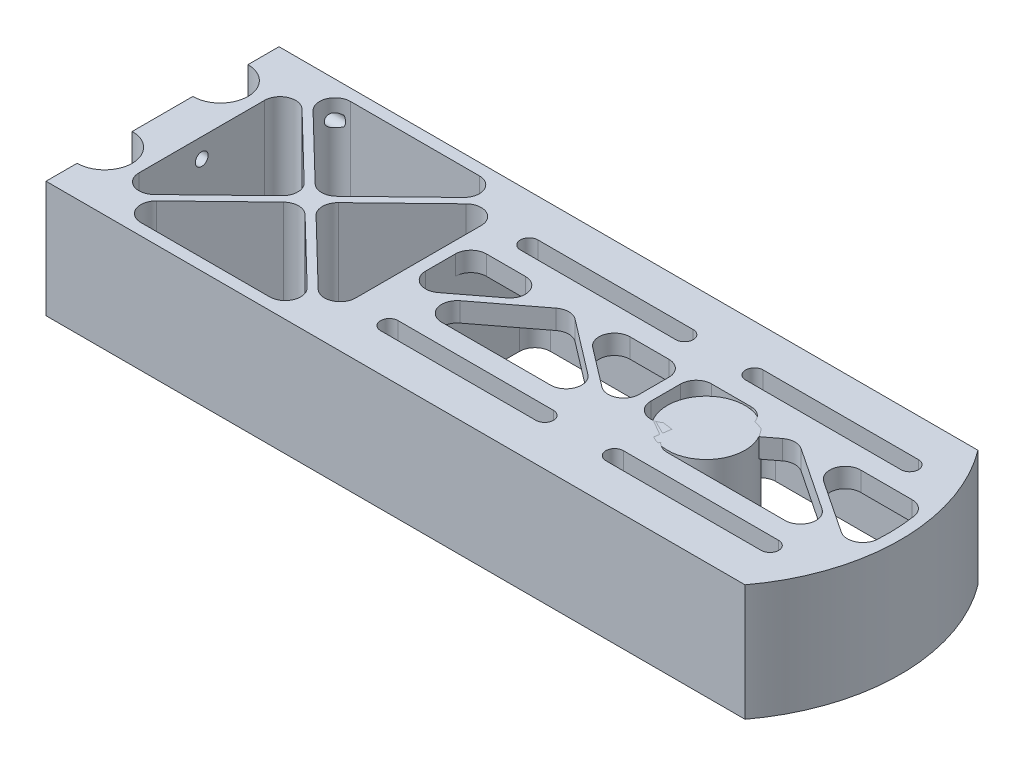
from build123d import *

# Parameters (mm, degrees)
EXTRUDE_1_DEPTH      = 30
CUT_EXTRUDE_1_DEPTH  = 31
TEMP_R               = 10
EXTRUDE_2_DEPTH      = 30
EXTRUDE_3_DEPTH      = 5
EXTRUDE_4_DEPTH      = 30
SKETCH_6_W           = 3
SKETCH_6_H           = 54
EXTRUDE_5_DEPTH      = 30
EXTRUDE_6_DEPTH      = 30
SKETCH_9_W           = 3
SKETCH_9_H           = 54
EXTRUDE_8_DEPTH      = 25
EXTRUDE_8_DEPTH_BACK = 5
EXTRUDE_7_DEPTH      = 5
FILLET_1_R           = 4
FILLET_2_R           = 4
FILLET_3_R           = 4
EXTRUDE_9_DEPTH      = 5
M4X0_71_AT_2_COUNT   = 2
M4X0_71_AT_2_PITCH   = 25.75
M4X0_71_AT_3_COUNT   = 2
M4X0_71_AT_3_PITCH   = 51.5
M4X0_71_AT_4_COUNT   = 2
M4X0_71_AT_4_PITCH   = 55.247171873
M4X0_71_AT_5_COUNT   = 2
M4X0_71_AT_5_PITCH   = 32.60463924
M4X0_71_AT_6_COUNT   = 2
M4X0_71_AT_6_PITCH   = 20


with BuildPart() as part:
    # Эскиз1 → Бобышка-Вытянуть1 (new body)
    with BuildSketch(Plane(origin=(0, 0, 0), x_dir=(1, 0, 0), z_dir=(0, 1, 0))):
        with BuildLine():
            Line((0, 60), (180, 60))
            ThreePointArc((180, 60), (190, 30), (180, 0))
            Line((180, 0), (0, 0))
            Line((0, 0), (0, 8))
            ThreePointArc((0, 8), (7.1, 15.1), (0, 22.2))
            Line((0, 22.2), (0, 37.8))
            ThreePointArc((0, 37.8), (7.1, 44.9), (0, 52))
            Line((0, 52), (0, 60))
        make_face()
    extrude(amount=EXTRUDE_1_DEPTH)

    # Эскиз2 → Вырез-Вытянуть1 (cut, through all)
    with BuildSketch(Plane(origin=(0, 30, 0), x_dir=(1, 0, 0), z_dir=(0, 1, 0))):
        with BuildLine():
            Line((3, 3), (178.470768123, 3))
            ThreePointArc((178.470768123, 3), (187, 30), (178.470768123, 57))
            Line((178.470768123, 57), (3, 57))
            Line((3, 57), (3, 54.544169223))
            ThreePointArc((3, 54.544169223), (10.1, 44.9), (3, 35.255830777))
            Line((3, 35.255830777), (3, 24.744169223))
            ThreePointArc((3, 24.744169223), (10.1, 15.1), (3, 5.455830777))
            Line((3, 5.455830777), (3, 3))
        make_face()
    extrude(amount=-CUT_EXTRUDE_1_DEPTH, mode=Mode.SUBTRACT)

    # Эскиз3 → Бобышка-Вытянуть3 (add)
    with BuildSketch(Plane(origin=(0, 30, 0), x_dir=(1, 0, 0), z_dir=(0, 1, 0))):
        with BuildLine():
            Line((178.470768123, 57), (68.916586692, 57))
            Line((68.916586692, 57), (68.916586692, 40.5))
            Line((68.916586692, 40.5), (185.812116301, 40.5))
            ThreePointArc((185.812116301, 40.5), (182.941397878, 49.105924428), (178.470768123, 57))
        make_face()
        with BuildLine():
            Line((116.416586692, 43.5), (76.416586692, 43.5))
            ThreePointArc((76.416586692, 43.5), (71.916586692, 48), (76.416586692, 52.5))
            Line((76.416586692, 52.5), (116.416586692, 52.5))
            ThreePointArc((116.416586692, 52.5), (120.916586692, 48), (116.416586692, 43.5))
        make_face(mode=Mode.SUBTRACT)
        with BuildLine():
            ThreePointArc((174.416586692, 52.5), (178.916586692, 48), (174.416586692, 43.5))
            Line((174.416586692, 43.5), (134.416586692, 43.5))
            ThreePointArc((134.416586692, 43.5), (129.916586692, 48), (134.416586692, 52.5))
            Line((134.416586692, 52.5), (174.416586692, 52.5))
        make_face(mode=Mode.SUBTRACT)
        with BuildLine():
            ThreePointArc((178.470768123, 3), (182.941397878, 10.894075572), (185.812116301, 19.5))
            Line((185.812116301, 19.5), (68.916586692, 19.5))
            Line((68.916586692, 19.5), (68.916586692, 3))
            Line((68.916586692, 3), (178.470768123, 3))
        make_face()
        with BuildLine():
            ThreePointArc((76.416586692, 7.5), (71.916586692, 12), (76.416586692, 16.5))
            Line((76.416586692, 16.5), (116.416586692, 16.5))
            ThreePointArc((116.416586692, 16.5), (120.916586692, 12), (116.416586692, 7.5))
            Line((116.416586692, 7.5), (76.416586692, 7.5))
        make_face(mode=Mode.SUBTRACT)
        with BuildLine():
            Line((134.416586692, 16.5), (174.416586692, 16.5))
            ThreePointArc((174.416586692, 16.5), (178.916586692, 12), (174.416586692, 7.5))
            Line((174.416586692, 7.5), (134.416586692, 7.5))
            ThreePointArc((134.416586692, 7.5), (129.916586692, 12), (134.416586692, 16.5))
        make_face(mode=Mode.SUBTRACT)
    extrude(amount=-EXTRUDE_3_DEPTH)

    # Эскиз4 → Бобышка-Вытянуть4 (add, through all)
    with BuildSketch(Plane(origin=(0, 30, 0), x_dir=(1, 0, 0), z_dir=(0, 1, 0))):
        with BuildLine():
            Line((10.1, 57), (3, 57))
            Line((3, 57), (3, 54.544169223))
            ThreePointArc((3, 54.544169223), (8.133572401, 50.887904475), (10.1, 44.9))
            Line((10.1, 44.9), (10.1, 57))
        make_face()
        with BuildLine():
            Line((10.1, 15.099999916), (10.1, 44.9))
            ThreePointArc((10.1, 44.9), (8.133572401, 38.912095525), (3, 35.255830777))
            Line((3, 35.255830777), (3, 24.744169223))
            ThreePointArc((3, 24.744169223), (8.133572426, 21.087904441), (10.1, 15.099999916))
        make_face()
        with BuildLine():
            Line((10.1, 3), (10.1, 15.099999916))
            ThreePointArc((10.1, 15.099999916), (8.133572376, 9.112095491), (3, 5.455830777))
            Line((3, 5.455830777), (3, 3))
            Line((3, 3), (10.1, 3))
        make_face()
    extrude(amount=-EXTRUDE_4_DEPTH)

    # Эскиз6 → Бобышка-Вытянуть5 (add, through all)
    with BuildSketch(Plane(origin=(0, 30, 0), x_dir=(1, 0, 0), z_dir=(0, 1, 0))):
        with Locations((67.416586692, 30)):
            Rectangle(SKETCH_6_W, SKETCH_6_H)
    extrude(amount=-EXTRUDE_5_DEPTH)

    # Эскиз7 → Бобышка-Вытянуть6 (add, through all)
    with BuildSketch(Plane(origin=(0, 30, 0), x_dir=(1, 0, 0), z_dir=(0, 1, 0))):
        Polygon((10.1, 55.608609353), (36.57009563, 30), (10.1, 4.391390647), (10.1, 3), (11.538197716, 3), (38.008293346, 28.608609353), (64.478388976, 3), (65.916586692, 3), (65.916586692, 4.391390647), (39.446491062, 30), (65.916586692, 55.608609353), (65.916586692, 57), (64.478388976, 57), (38.008293346, 31.391390647), (11.538197716, 57), (10.1, 57), align=None)
    extrude(amount=-EXTRUDE_6_DEPTH)

    # Эскиз9 → Бобышка-Вытянуть8 (add, two sides)
    with BuildSketch(Plane.XZ.offset(-25)) as extrude_8_sk:
        with Locations((125.416586692, -30)):
            Rectangle(SKETCH_9_W, SKETCH_9_H)
    extrude(amount=EXTRUDE_8_DEPTH)
    extrude(extrude_8_sk.sketch, amount=-EXTRUDE_8_DEPTH_BACK)

    # Эскиз8 → Бобышка-Вытянуть7 (add)
    with BuildSketch(Plane(origin=(0, 30, 0), x_dir=(1, 0, 0), z_dir=(0, 1, 0))):
        Polygon((70.564267671, 19.5), (96.416586692, 39.241770889), (122.268905713, 19.5), (123.916586692, 19.5), (123.916586692, 20.758229111), (98.064267671, 40.5), (94.768905713, 40.5), (68.916586692, 20.758229111), (68.916586692, 19.5), align=None)
        with BuildLine():
            Line((128.569887735, 19.5), (154.477979009, 39.178204914))
            Line((154.477979009, 39.178204914), (184.008770478, 19.5))
            Line((184.008770478, 19.5), (185.812116301, 19.5))
            ThreePointArc((185.812116301, 19.5), (185.929117822, 20.024222532), (186.040120933, 20.549747915))
            Line((186.040120933, 20.549747915), (156.101072293, 40.5))
            Line((156.101072293, 40.5), (152.911636662, 40.5))
            Line((152.911636662, 40.5), (126.916586692, 20.755746568))
            Line((126.916586692, 20.755746568), (126.916586692, 19.5))
            Line((126.916586692, 19.5), (128.569887735, 19.5))
        make_face()
    extrude(amount=-EXTRUDE_7_DEPTH)

    # Скругление1
    fillet_1_edges = [part.edges().sort_by_distance(p)[0] for p in [
        (10.1, 15, -4.391390647),
        (36.57009563, 15, -30),
        (10.1, 15, -55.608609353),
        (11.538197716, 15, -57),
        (38.008293346, 15, -31.391390647),
        (64.478388976, 15, -57),
        (65.916586692, 15, -55.608609353),
        (39.446491062, 15, -30),
        (65.916586692, 15, -4.391390647),
        (64.478388976, 15, -3),
        (38.008293346, 15, -28.608609353),
        (11.538197716, 15, -3),
    ]]
    fillet(fillet_1_edges, radius=FILLET_1_R)

    # Скругление2
    fillet_2_edges = [part.edges().sort_by_distance(p)[0] for p in [
        (68.916586692, 12.5, -57),
        (68.916586692, 12.5, -3),
        (123.916586692, 12.5, -57),
        (126.916586692, 12.5, -3),
        (123.916586692, 12.5, -3),
        (126.916586692, 12.5, -57),
        (178.470768123, 12.5, -57),
        (178.470768123, 12.5, -3),
    ]]
    fillet(fillet_2_edges, radius=FILLET_2_R)

    # Скругление3
    fillet_3_edges = [part.edges().sort_by_distance(p)[0] for p in [
        (123.916586692, 27.5, -40.5),
        (126.916586692, 27.5, -40.5),
        (70.564267671, 27.5, -19.5),
        (68.916586692, 27.5, -20.758229111),
        (94.768905713, 27.5, -40.5),
        (98.064267671, 27.5, -40.5),
        (123.916586692, 27.5, -20.758229111),
        (122.268905713, 27.5, -19.5),
        (96.416586692, 27.5, -39.241770889),
        (128.569887735, 27.5, -19.5),
        (126.916586692, 27.5, -20.755746568),
        (152.911636662, 27.5, -40.5),
        (156.101072293, 27.5, -40.5),
        (186.040120933, 27.5, -20.549747915),
        (184.008770478, 27.5, -19.5),
        (154.477979009, 27.5, -39.178204914),
        (68.916586692, 27.5, -40.5),
        (185.812116301, 27.5, -40.5),
    ]]
    fillet(fillet_3_edges, radius=FILLET_3_R)

    # Эскиз10 → Бобышка-Вытянуть9 (add)
    with BuildSketch(Plane(origin=(0, 30, 0), x_dir=(1, 0, 0), z_dir=(0, 1, 0))):
        with BuildLine():
            Line((76.416586692, 52.5), (116.416586692, 52.5))
            ThreePointArc((116.416586692, 52.5), (120.916586692, 48), (116.416586692, 43.5))
            Line((116.416586692, 43.5), (76.416586692, 43.5))
            ThreePointArc((76.416586692, 43.5), (71.916586692, 48), (76.416586692, 52.5))
        make_face()
        with BuildLine():
            Line((116.416586692, 50.25), (76.416586692, 50.25))
            ThreePointArc((76.416586692, 50.25), (74.166586692, 48), (76.416586692, 45.75))
            Line((76.416586692, 45.75), (116.416586692, 45.75))
            ThreePointArc((116.416586692, 45.75), (118.666586692, 48), (116.416586692, 50.25))
        make_face(mode=Mode.SUBTRACT)
        with BuildLine():
            Line((174.416586692, 52.5), (134.416586692, 52.5))
            ThreePointArc((134.416586692, 52.5), (129.916586692, 48), (134.416586692, 43.5))
            Line((134.416586692, 43.5), (174.416586692, 43.5))
            ThreePointArc((174.416586692, 43.5), (178.916586692, 48), (174.416586692, 52.5))
        make_face()
        with BuildLine():
            Line((174.416586692, 45.75), (134.416586692, 45.75))
            ThreePointArc((134.416586692, 45.75), (132.166586692, 48), (134.416586692, 50.25))
            Line((134.416586692, 50.25), (174.416586692, 50.25))
            ThreePointArc((174.416586692, 50.25), (176.666586692, 48), (174.416586692, 45.75))
        make_face(mode=Mode.SUBTRACT)
        with BuildLine():
            Line((76.416586692, 16.5), (116.416586692, 16.5))
            ThreePointArc((116.416586692, 16.5), (120.916586692, 12), (116.416586692, 7.5))
            Line((116.416586692, 7.5), (76.416586692, 7.5))
            ThreePointArc((76.416586692, 7.5), (71.916586692, 12), (76.416586692, 16.5))
        make_face()
        with BuildLine():
            Line((76.416586692, 9.75), (116.416586692, 9.75))
            ThreePointArc((116.416586692, 9.75), (118.666586692, 12), (116.416586692, 14.25))
            Line((116.416586692, 14.25), (76.416586692, 14.25))
            ThreePointArc((76.416586692, 14.25), (74.166586692, 12), (76.416586692, 9.75))
        make_face(mode=Mode.SUBTRACT)
        with BuildLine():
            Line((174.416586692, 16.5), (134.416586692, 16.5))
            ThreePointArc((134.416586692, 16.5), (129.916586692, 12), (134.416586692, 7.5))
            Line((134.416586692, 7.5), (174.416586692, 7.5))
            ThreePointArc((174.416586692, 7.5), (178.916586692, 12), (174.416586692, 16.5))
        make_face()
        with BuildLine():
            Line((174.416586692, 14.25), (134.416586692, 14.25))
            ThreePointArc((134.416586692, 14.25), (132.166586692, 12), (134.416586692, 9.75))
            Line((134.416586692, 9.75), (174.416586692, 9.75))
            ThreePointArc((174.416586692, 9.75), (176.666586692, 12), (174.416586692, 14.25))
        make_face(mode=Mode.SUBTRACT)
    extrude(amount=-EXTRUDE_9_DEPTH)

    # Эскиз14 → Отверстие обработанное метчиком M4x0.71 (revolve, cut)
    with BuildSketch(Plane(origin=(0, 25, -55.75), x_dir=(0, 0, 1), z_dir=(0, 1, 0))):
        Polygon((0, 0), (0, 20.991420021), (1.65, 20), (1.65, 0), align=None)
    m4x0_71 = revolve(axis=Axis((-6.35, 25, -55.75), (1, 0, 0)), mode=Mode.SUBTRACT)

    # Отверстие обработанное метчиком M4x0.71 at 2: Отверстие обработанное метчиком M4x0.71 ×2
    with Locations(*[(0, 0, i * M4X0_71_AT_2_PITCH) for i in range(1, M4X0_71_AT_2_COUNT)]):
        add(m4x0_71, mode=Mode.SUBTRACT)

    # Отверстие обработанное метчиком M4x0.71 at 3: Отверстие обработанное метчиком M4x0.71 ×2
    with Locations(*[(0, 0, i * M4X0_71_AT_3_PITCH) for i in range(1, M4X0_71_AT_3_COUNT)]):
        add(m4x0_71, mode=Mode.SUBTRACT)

    # Отверстие обработанное метчиком M4x0.71 at 4: Отверстие обработанное метчиком M4x0.71 ×2
    with Locations(*[Vector(0, -0.362009481, 0.932174413) * (i * M4X0_71_AT_4_PITCH) for i in range(1, M4X0_71_AT_4_COUNT)]):
        add(m4x0_71, mode=Mode.SUBTRACT)

    # Отверстие обработанное метчиком M4x0.71 at 5: Отверстие обработанное метчиком M4x0.71 ×2
    with Locations(*[Vector(0, -0.613409639, 0.789764911) * (i * M4X0_71_AT_5_PITCH) for i in range(1, M4X0_71_AT_5_COUNT)]):
        add(m4x0_71, mode=Mode.SUBTRACT)

    # Отверстие обработанное метчиком M4x0.71 at 6: Отверстие обработанное метчиком M4x0.71 ×2
    with Locations(*[(0, -i * M4X0_71_AT_6_PITCH, 0) for i in range(1, M4X0_71_AT_6_COUNT)]):
        add(m4x0_71, mode=Mode.SUBTRACT)


with BuildPart() as body_2:
    # Temp → Бобышка-Вытянуть2 (new body)
    with BuildSketch(Plane(origin=(0, 30, 0), x_dir=(1, 0, 0), z_dir=(0, 1, 0))):
        with Locations((140, 30)):
            Circle(TEMP_R)
    extrude(amount=-EXTRUDE_2_DEPTH)


solid = Compound([part.part, body_2.part])
